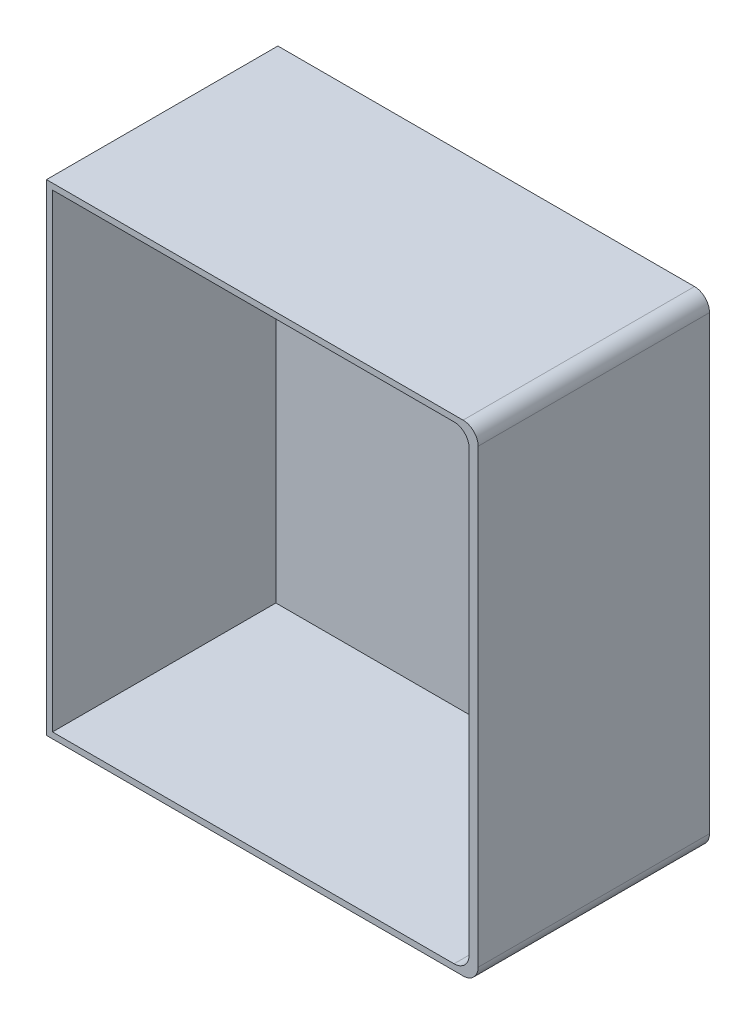
from build123d import *

# Parameters (mm, degrees)
SKETCH_1_W          = 86
SKETCH_1_H          = 95.9
EXTRUDE_1_DEPTH     = 46.1
EXTRUDE_2_DEPTH     = 5
SKETCH_3_W          = 83
SKETCH_3_H          = 93.5
CUT_EXTRUDE_1_DEPTH = 44.5
FILLET_1_R          = 3


with BuildPart() as part:
    # Эскиз1 → Бобышка-Вытянуть1 (new body)
    with BuildSketch(Plane.XY):
        Rectangle(SKETCH_1_W, SKETCH_1_H)
    extrude(amount=EXTRUDE_1_DEPTH)

    # Эскиз2 → Бобышка-Вытянуть2 (add)
    with BuildSketch(Plane.XY):
        with BuildLine():
            Line((-43, 42.95), (-43, 35.870635623))
            ThreePointArc((-43, 35.870635623), (-53.275135929, 0), (-43, -35.870635623))
            Line((-43, -35.870635623), (-43, -42.95))
            ThreePointArc((-43, -42.95), (-57.275135929, 0), (-43, 42.95))
        make_face()
    extrude(amount=EXTRUDE_2_DEPTH)

    # Эскиз3 → Вырез-Вытянуть1 (cut)
    with BuildSketch(Plane.XY.offset(46.1)):
        with Locations((-0.3, 0)):
            Rectangle(SKETCH_3_W, SKETCH_3_H)
    extrude(amount=-CUT_EXTRUDE_1_DEPTH, mode=Mode.SUBTRACT)

    # Скругление1
    fillet_1_edges = [part.edges().sort_by_distance(p)[0] for p in [
        (41.2, 46.75, 23.85),
        (41.2, -46.75, 23.85),
        (43, 47.95, 23.05),
        (43, -47.95, 23.05),
    ]]
    fillet(fillet_1_edges, radius=FILLET_1_R)


solid = part.part
